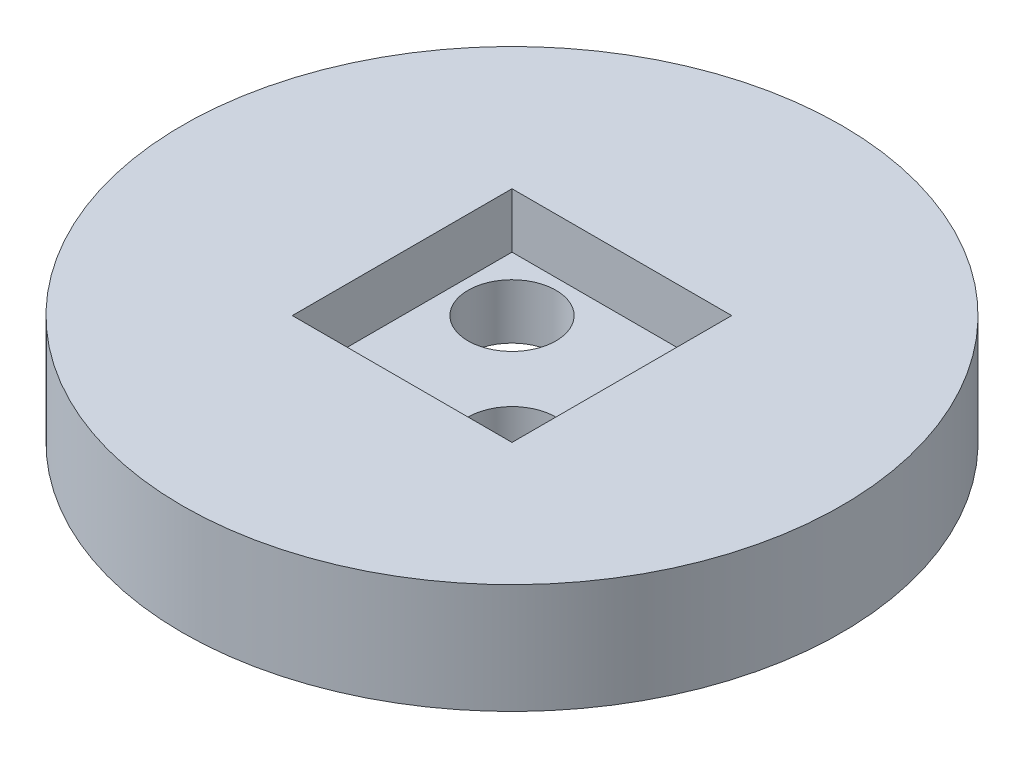
from build123d import *

# Parameters (mm, degrees)
SKETCH1_R           = 15
SKETCH1_W           = 10
SKETCH1_H           = 10
BOSS_EXTRUDE1_DEPTH = 5
SKETCH2_W           = 10
SKETCH2_H           = 2.5
BOSS_EXTRUDE2_DEPTH = 10
SKETCH3_R           = 2
CUT_EXTRUDE1_DEPTH  = 10


with BuildPart() as part:
    # Sketch1 → Boss-Extrude1 (new body)
    with BuildSketch(Plane(origin=(0, 0, 0), x_dir=(1, 0, 0), z_dir=(0, 1, 0))):
        Circle(SKETCH1_R)
        Rectangle(SKETCH1_W, SKETCH1_H, mode=Mode.SUBTRACT)
    extrude(amount=BOSS_EXTRUDE1_DEPTH)

    # Sketch2 → Boss-Extrude2 (add)
    with BuildSketch(Plane.XY.offset(-5)):
        with Locations((0, 1.25)):
            Rectangle(SKETCH2_W, SKETCH2_H)
    extrude(amount=BOSS_EXTRUDE2_DEPTH)

    # Sketch3 → Cut-Extrude1 (cut)
    with BuildSketch(Plane(origin=(0, 2.5, 0), x_dir=(1, 0, 0), z_dir=(0, 1, 0))):
        with Locations((-2.5, 2.5)):
            Circle(SKETCH3_R)
        with Locations((2.5, -2.5)):
            Circle(SKETCH3_R)
    extrude(amount=-CUT_EXTRUDE1_DEPTH, mode=Mode.SUBTRACT)


solid = part.part
